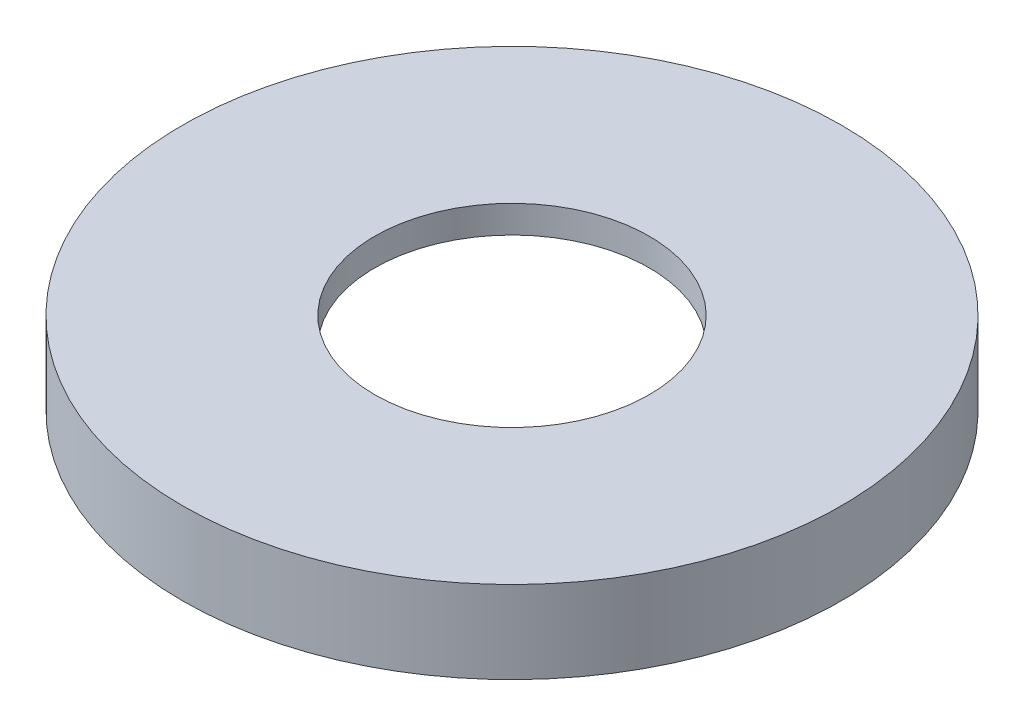
from build123d import *

# Parameters (mm, degrees)
SKETCH1_R           = 38.1
SKETCH1_R_2         = 33.0835
BOSS_EXTRUDE1_DEPTH = 6.35
SKETCH2_R           = 38.1
SKETCH2_R_2         = 15.875
BOSS_EXTRUDE2_DEPTH = 3.175


with BuildPart() as part:
    # Sketch1 → Boss-Extrude1 (new body)
    with BuildSketch(Plane(origin=(0, 0, 0), x_dir=(1, 0, 0), z_dir=(0, 1, 0))):
        Circle(SKETCH1_R)
        Circle(SKETCH1_R_2, mode=Mode.SUBTRACT)
    extrude(amount=-BOSS_EXTRUDE1_DEPTH)

    # Sketch2 → Boss-Extrude2 (add)
    with BuildSketch(Plane(origin=(0, 0, 0), x_dir=(1, 0, 0), z_dir=(0, 1, 0))):
        Circle(SKETCH2_R)
        Circle(SKETCH2_R_2, mode=Mode.SUBTRACT)
    extrude(amount=BOSS_EXTRUDE2_DEPTH)


solid = part.part
